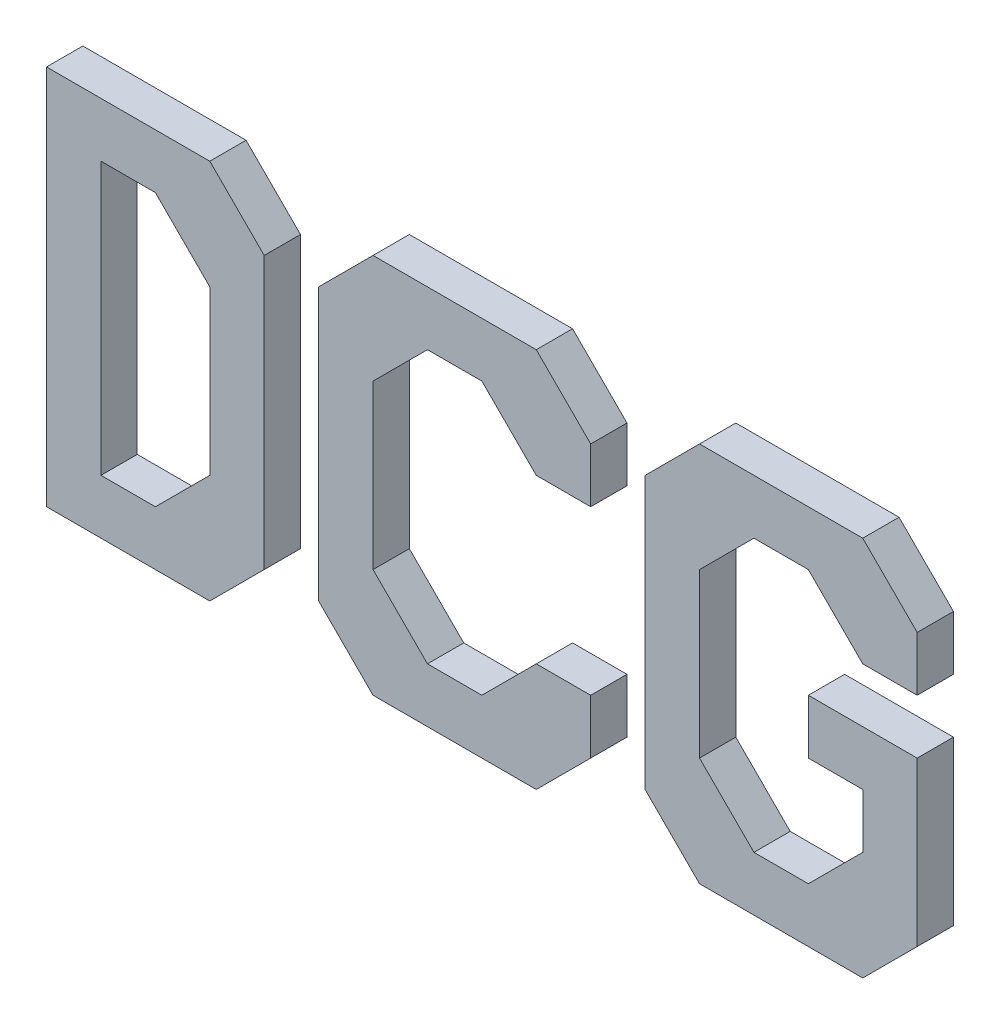
from build123d import *

# Parameters (mm, degrees)
EXTRUDE1_DEPTH   = 10
EXTRUDE1_2_DEPTH = 10
EXTRUDE1_3_DEPTH = 10


with BuildPart() as part:
    # Sketch2 → Extrude1 (new body)
    with BuildSketch(Plane.XY):
        Polygon((0, 0), (0, 105), (45, 105), (60, 90), (60, 15), (45, 0), align=None)
        Polygon((15, 90), (30, 90), (45, 75), (45, 30), (30, 15), (15, 15), align=None, mode=Mode.SUBTRACT)
    extrude(amount=EXTRUDE1_DEPTH)


with BuildPart() as body_2:
    # Sketch2 → Extrude1 2 (new body)
    with BuildSketch(Plane.XY):
        Polygon((90, 0), (75, 15), (75, 90), (90, 105), (135, 105), (150, 90), (150, 75), (135, 75), (120, 90), (105, 90), (90, 75), (90, 30), (105, 15), (120, 15), (135, 30), (150, 30), (150, 15), (135, 0), align=None)
    extrude(amount=EXTRUDE1_2_DEPTH)


with BuildPart() as body_3:
    # Sketch2 → Extrude1 3 (new body)
    with BuildSketch(Plane.XY):
        Polygon((180, 0), (165, 15), (165, 90), (180, 105), (225, 105), (240, 90), (240, 75), (225, 75), (210, 90), (195, 90), (180, 75), (180, 30), (195, 15), (210, 15), (225, 30), (225, 45), (210, 45), (210, 60), (240, 60), (240, 15), (225, 0), align=None)
    extrude(amount=EXTRUDE1_3_DEPTH)


solid = Compound([part.part, body_2.part, body_3.part])
